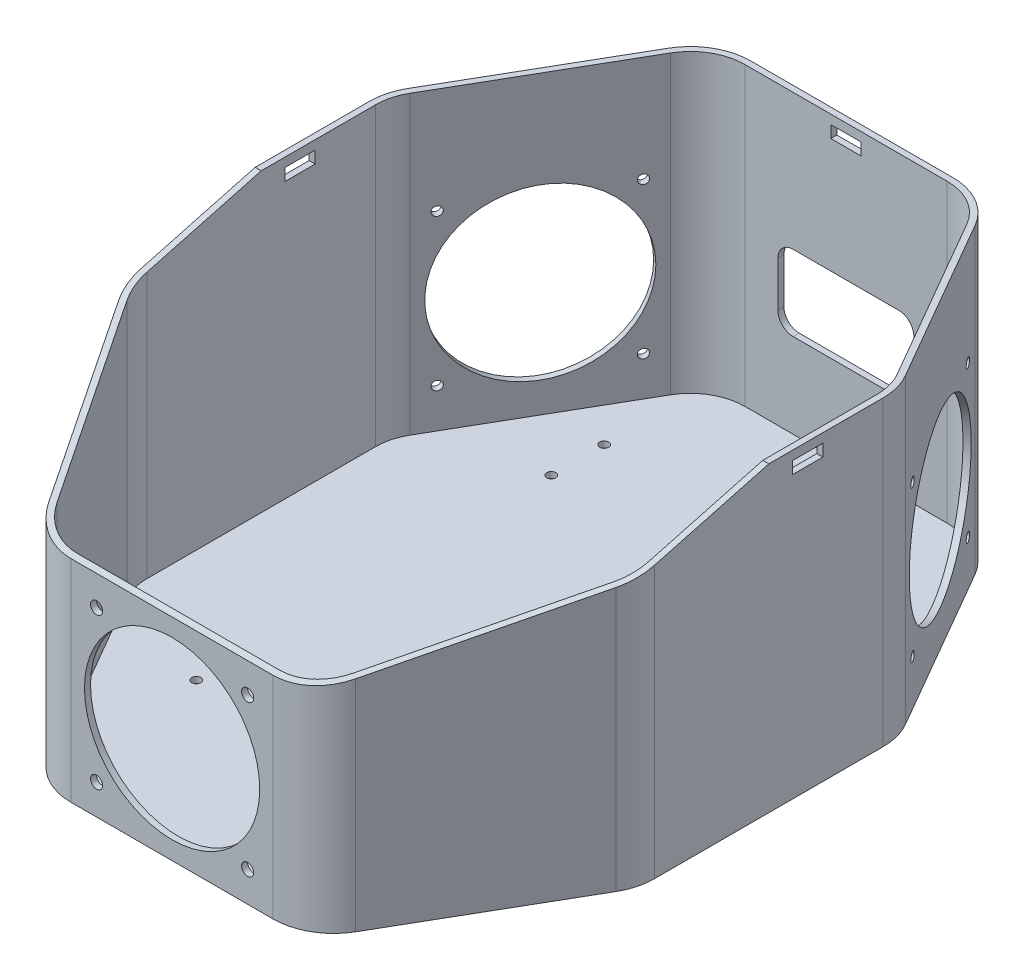
from build123d import *

# Parameters (mm, degrees)
SALIENTE_EXTRUIR1_DEPTH     = 100
VACIADO2_T                  = -2
CROQUIS2_R                  = 1.5
CORTAR_EXTRUIR1_DEPTH       = 101
CORTAR_EXTRUIR1_DEPTH_BACK  = 1
CROQUIS8_R                  = 28
CROQUIS8_R_2                = 1.5
CORTAR_EXTRUIR6_DEPTH       = 130.862159322
CORTAR_EXTRUIR7_DEPTH       = 113.5
CORTAR_EXTRUIR8_DEPTH       = 86
CORTAR_EXTRUIR8_DEPTH_BACK  = 86
CROQUIS11_R                 = 29
CROQUIS11_R_2               = 2
CORTAR_EXTRUIR9_DEPTH       = 113.5
CROQUIS13_W                 = 10
CROQUIS13_H                 = 4
CORTAR_EXTRUIR10_DEPTH      = 113.5
CROQUIS14_W                 = 10
CROQUIS14_H                 = 4
CORTAR_EXTRUIR11_DEPTH      = 86
CORTAR_EXTRUIR11_DEPTH_BACK = 86


with BuildPart() as part:
    # Croquis1 → Saliente-Extruir1 (new body)
    with BuildSketch(Plane(origin=(0, 0, 0), x_dir=(1, 0, 0), z_dir=(0, 1, 0))):
        with BuildLine():
            Line((-82.320508076, 47.858983849), (-50.773502692, 102.5))
            ThreePointArc((-50.773502692, 102.5), (-43.452994616, 109.820508076), (-33.452994616, 112.5))
            Line((-33.452994616, 112.5), (33.452994616, 112.5))
            ThreePointArc((33.452994616, 112.5), (43.452994616, 109.820508076), (50.773502692, 102.5))
            Line((50.773502692, 102.5), (82.320508076, 47.858983849))
            ThreePointArc((82.320508076, 47.858983849), (84.318516526, 43.035364751), (85, 37.858983849))
            Line((85, 37.858983849), (85, -37.858983849))
            ThreePointArc((85, -37.858983849), (84.318516526, -43.035364751), (82.320508076, -47.858983849))
            Line((82.320508076, -47.858983849), (50.773502692, -102.5))
            ThreePointArc((50.773502692, -102.5), (43.452994616, -109.820508076), (33.452994616, -112.5))
            Line((33.452994616, -112.5), (-33.452994616, -112.5))
            ThreePointArc((-33.452994616, -112.5), (-43.452994616, -109.820508076), (-50.773502692, -102.5))
            Line((-50.773502692, -102.5), (-82.320508076, -47.858983849))
            ThreePointArc((-82.320508076, -47.858983849), (-84.318516526, -43.035364751), (-85, -37.858983849))
            Line((-85, -37.858983849), (-85, 37.858983849))
            ThreePointArc((-85, 37.858983849), (-84.318516526, 43.035364751), (-82.320508076, 47.858983849))
        make_face()
    extrude(amount=SALIENTE_EXTRUIR1_DEPTH)

    # Vaciado2
    vaciado2_openings = [part.faces().sort_by_distance(p)[0] for p in [
        (0, 100, 0),
    ]]
    offset(amount=VACIADO2_T, openings=vaciado2_openings, kind=Kind.INTERSECTION)

    # Croquis2 → Cortar-Extruir1 (cut, two sides)
    with BuildSketch(Plane(origin=(0, 0, 0), x_dir=(1, 0, 0), z_dir=(0, 1, 0))) as cortar_extruir1_sk:
        with Locations((-45.75, 76.25)):
            Circle(CROQUIS2_R)
        with Locations((-45.75, 58.75)):
            Circle(CROQUIS2_R)
        with Locations((45.75, 58.75)):
            Circle(CROQUIS2_R)
        with Locations((-45.75, -58.75)):
            Circle(CROQUIS2_R)
        with Locations((45.75, -58.75)):
            Circle(CROQUIS2_R)
        with Locations((45.75, -76.25)):
            Circle(CROQUIS2_R)
    extrude(amount=CORTAR_EXTRUIR1_DEPTH, mode=Mode.SUBTRACT)
    extrude(cortar_extruir1_sk.sketch, amount=-CORTAR_EXTRUIR1_DEPTH_BACK, mode=Mode.SUBTRACT)

    # Croquis8 → Cortar-Extruir6 (cut, through all)
    with BuildSketch(Plane(origin=(0, 0, 0), x_dir=(-0.5, 0, -0.866025404), z_dir=(0.866025404, 0, -0.5))):
        with Locations((31.833847158, 40)):
            Circle(CROQUIS8_R)
        with Locations((6.833847158, 65)):
            Circle(CROQUIS8_R_2)
        with Locations((56.833847158, 65)):
            Circle(CROQUIS8_R_2)
        with Locations((6.833847158, 15)):
            Circle(CROQUIS8_R_2)
        with Locations((56.833847158, 15)):
            Circle(CROQUIS8_R_2)
    cortar_extruir6 = extrude(amount=CORTAR_EXTRUIR6_DEPTH, mode=Mode.SUBTRACT)

    # Simetría1: Cortar-Extruir6 across plane
    add(cortar_extruir6.mirror(Plane(origin=(0, 0, 0), x_dir=(0, 0, 1), z_dir=(1, 0, 0))), mode=Mode.SUBTRACT)

    # Croquis9 → Cortar-Extruir7 (cut, through all)
    with BuildSketch(Plane.XY):
        with BuildLine():
            Line((17.5, 55), (-17.5, 55))
            ThreePointArc((-17.5, 55), (-21.035533906, 53.535533906), (-22.5, 50))
            Line((-22.5, 50), (-22.5, 35))
            ThreePointArc((-22.5, 35), (-21.035533906, 31.464466094), (-17.5, 30))
            Line((-17.5, 30), (17.5, 30))
            ThreePointArc((17.5, 30), (21.035533906, 31.464466094), (22.5, 35))
            Line((22.5, 35), (22.5, 50))
            ThreePointArc((22.5, 50), (21.035533906, 53.535533906), (17.5, 55))
        make_face()
    extrude(amount=-CORTAR_EXTRUIR7_DEPTH, mode=Mode.SUBTRACT)

    # Croquis10 → Cortar-Extruir8 (cut, two sides)
    with BuildSketch(Plane(origin=(0, 0, 0), x_dir=(0, 0, -1), z_dir=(1, 0, 0))) as cortar_extruir8_sk:
        Polygon((0, 100), (-148.82762011, 60.12175938), (-148.82762011, 114.287226581), (0, 114.287226581), align=None)
    extrude(amount=CORTAR_EXTRUIR8_DEPTH, mode=Mode.SUBTRACT)
    extrude(cortar_extruir8_sk.sketch, amount=-CORTAR_EXTRUIR8_DEPTH_BACK, mode=Mode.SUBTRACT)

    # Croquis11 → Cortar-Extruir9 (cut, through all)
    with BuildSketch(Plane.XY):
        with Locations((0, 35)):
            Circle(CROQUIS11_R)
        with Locations((25, 10)):
            Circle(CROQUIS11_R_2)
        with Locations((-25, 10)):
            Circle(CROQUIS11_R_2)
        with Locations((-25, 60)):
            Circle(CROQUIS11_R_2)
        with Locations((25, 60)):
            Circle(CROQUIS11_R_2)
    extrude(amount=CORTAR_EXTRUIR9_DEPTH, mode=Mode.SUBTRACT)

    # Croquis13 → Cortar-Extruir10 (cut, through all)
    with BuildSketch(Plane.XY):
        with Locations((0, 95)):
            Rectangle(CROQUIS13_W, CROQUIS13_H)
    extrude(amount=-CORTAR_EXTRUIR10_DEPTH, mode=Mode.SUBTRACT)

    # Croquis14 → Cortar-Extruir11 (cut, two sides)
    with BuildSketch(Plane(origin=(0, 0, 0), x_dir=(0, 0, -1), z_dir=(1, 0, 0))) as cortar_extruir11_sk:
        with Locations((12.858983849, 95)):
            Rectangle(CROQUIS14_W, CROQUIS14_H)
    extrude(amount=CORTAR_EXTRUIR11_DEPTH, mode=Mode.SUBTRACT)
    extrude(cortar_extruir11_sk.sketch, amount=-CORTAR_EXTRUIR11_DEPTH_BACK, mode=Mode.SUBTRACT)


solid = part.part
